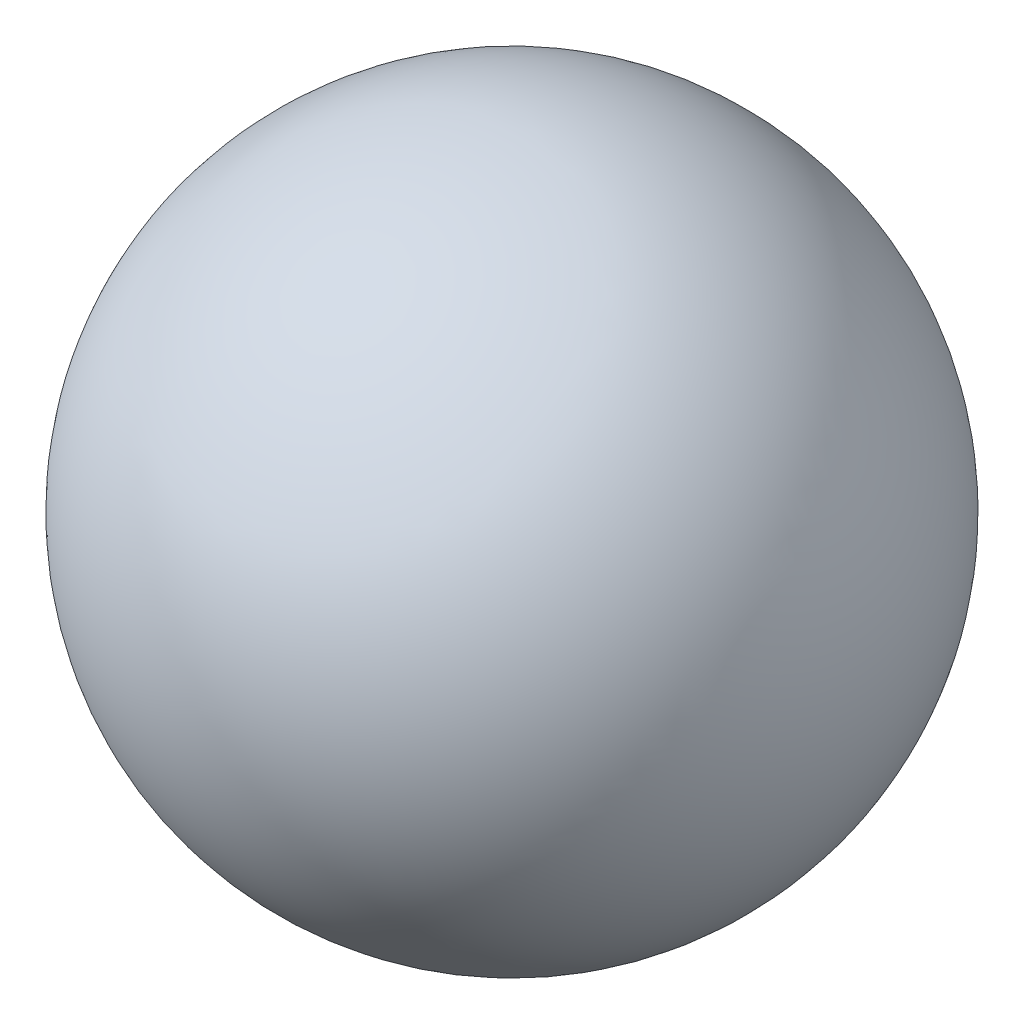
from build123d import *


with BuildPart() as part:
    # Sketch1 → Revolve1 (revolve)
    with BuildSketch(Plane.XY):
        with BuildLine():
            Line((-12.7, 0), (12.7, 0))
            ThreePointArc((12.7, 0), (0, 12.7), (-12.7, 0))
        make_face()
    revolve(axis=Axis((-12.7, 0, 0), (1, 0, 0)))


solid = part.part
